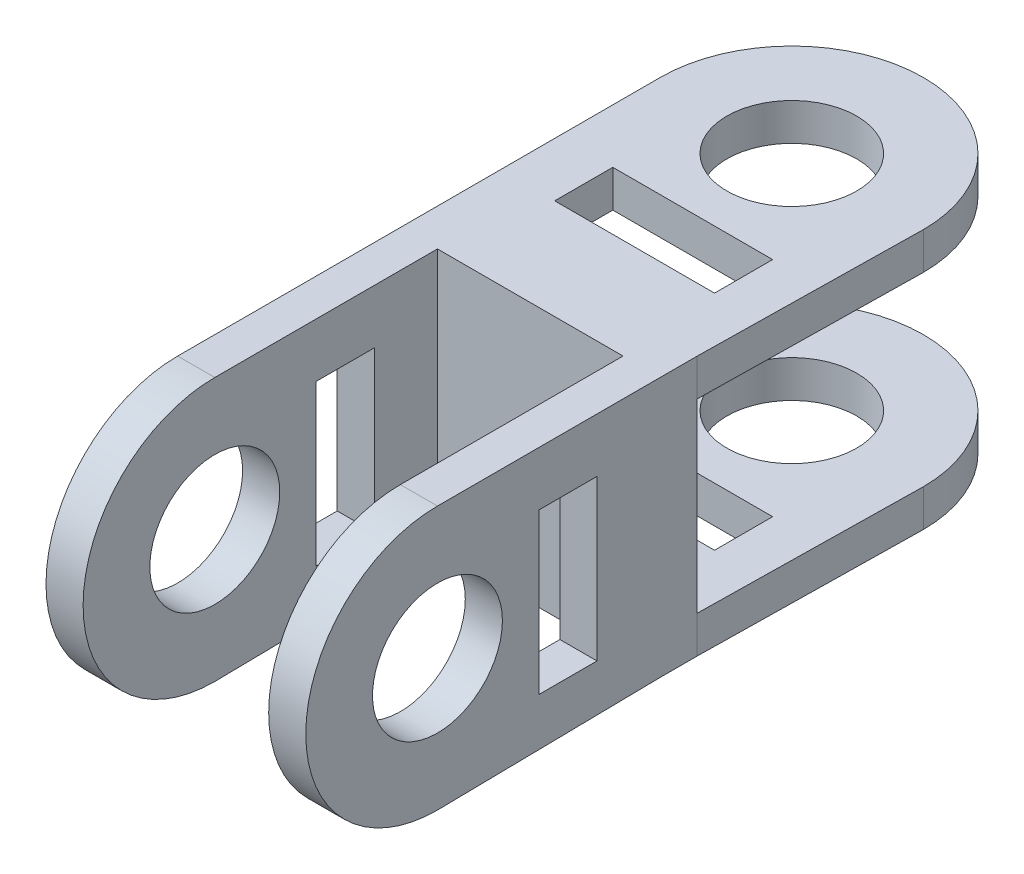
from build123d import *

# Parameters (mm, degrees)
SKETCH_1_W          = 70
SKETCH_1_H          = 70
EXTRUDE_1_DEPTH     = 10
SKETCH_2_R          = 17.5
SKETCH_2_W          = 15.660204931
SKETCH_2_H          = 43.06556356
EXTRUDE_2_DEPTH     = 35
SKETCH_2_2_R        = 17.5
SKETCH_2_2_W        = 15.660204931
SKETCH_2_2_H        = 43.06556356
CUT_EXTRUDE_1_DEPTH = 25
SKETCH_3_R          = 17.5
SKETCH_3_W          = 15.660204931
SKETCH_3_H          = 43.06556356
EXTRUDE_3_DEPTH     = 35
SKETCH_3_3_R        = 17.5
SKETCH_3_3_W        = 15.660204931
SKETCH_3_3_H        = 43.06556356
CUT_EXTRUDE_2_DEPTH = 25


with BuildPart() as part:
    # 草圖1 → 填料-伸長1 (new body)
    with BuildSketch(Plane.XY):
        Rectangle(SKETCH_1_W, SKETCH_1_H)
    extrude(amount=EXTRUDE_1_DEPTH)

    # 草圖2 → 填料-伸長2 (add, symmetric)
    with BuildSketch(Plane(origin=(0, 0, 0), x_dir=(0, 0, -1), z_dir=(1, 0, 0))):
        with BuildLine():
            Line((-10, 35), (-70, 35))
            ThreePointArc((-70, 35), (-105.476695364, -0.476695364), (-70, -35.953390728))
            Line((-70, -35.953390728), (-10, -35))
            Line((-10, -35), (-10, 35))
        make_face()
        with Locations((-70, -0.476695364)):
            Circle(SKETCH_2_R, mode=Mode.SUBTRACT)
        with Locations((-34.843422831, -1.110145808)):
            Rectangle(SKETCH_2_W, SKETCH_2_H, mode=Mode.SUBTRACT)
    extrude(amount=EXTRUDE_2_DEPTH, both=True)

    # 草圖2<2> → 除料-伸長1 (cut, symmetric)
    with BuildSketch(Plane(origin=(0, 0, 0), x_dir=(0, 0, -1), z_dir=(1, 0, 0))):
        with BuildLine():
            Line((-10, 35), (-70, 35))
            ThreePointArc((-70, 35), (-105.476695364, -0.476695364), (-70, -35.953390728))
            Line((-70, -35.953390728), (-10, -35))
            Line((-10, -35), (-10, 35))
        make_face()
        with Locations((-70, -0.476695364)):
            Circle(SKETCH_2_2_R, mode=Mode.SUBTRACT)
        with Locations((-34.843422831, -1.110145808)):
            Rectangle(SKETCH_2_2_W, SKETCH_2_2_H, mode=Mode.SUBTRACT)
    extrude(amount=CUT_EXTRUDE_1_DEPTH, both=True, mode=Mode.SUBTRACT)

    # 草圖3 → 填料-伸長3 (add, symmetric)
    with BuildSketch(Plane(origin=(0, 0, 10), x_dir=(0, 0, 1), z_dir=(0, -1, 0))):
        with BuildLine():
            Line((-10, 35), (-70, 35))
            ThreePointArc((-70, 35), (-105.476695364, -0.476695364), (-70, -35.953390728))
            Line((-70, -35.953390728), (-10, -35))
            Line((-10, -35), (-10, 35))
        make_face()
        with Locations((-70, -0.476695364)):
            Circle(SKETCH_3_R, mode=Mode.SUBTRACT)
        with Locations((-34.843422831, -1.110145808)):
            Rectangle(SKETCH_3_W, SKETCH_3_H, mode=Mode.SUBTRACT)
    extrude(amount=EXTRUDE_3_DEPTH, both=True)

    # 草圖3<3> → 除料-伸長2 (cut, symmetric)
    with BuildSketch(Plane(origin=(0, 0, 10), x_dir=(0, 0, 1), z_dir=(0, -1, 0))):
        with BuildLine():
            Line((-10, 35), (-70, 35))
            ThreePointArc((-70, 35), (-105.476695364, -0.476695364), (-70, -35.953390728))
            Line((-70, -35.953390728), (-10, -35))
            Line((-10, -35), (-10, 35))
        make_face()
        with Locations((-70, -0.476695364)):
            Circle(SKETCH_3_3_R, mode=Mode.SUBTRACT)
        with Locations((-34.843422831, -1.110145808)):
            Rectangle(SKETCH_3_3_W, SKETCH_3_3_H, mode=Mode.SUBTRACT)
    extrude(amount=CUT_EXTRUDE_2_DEPTH, both=True, mode=Mode.SUBTRACT)


solid = part.part
